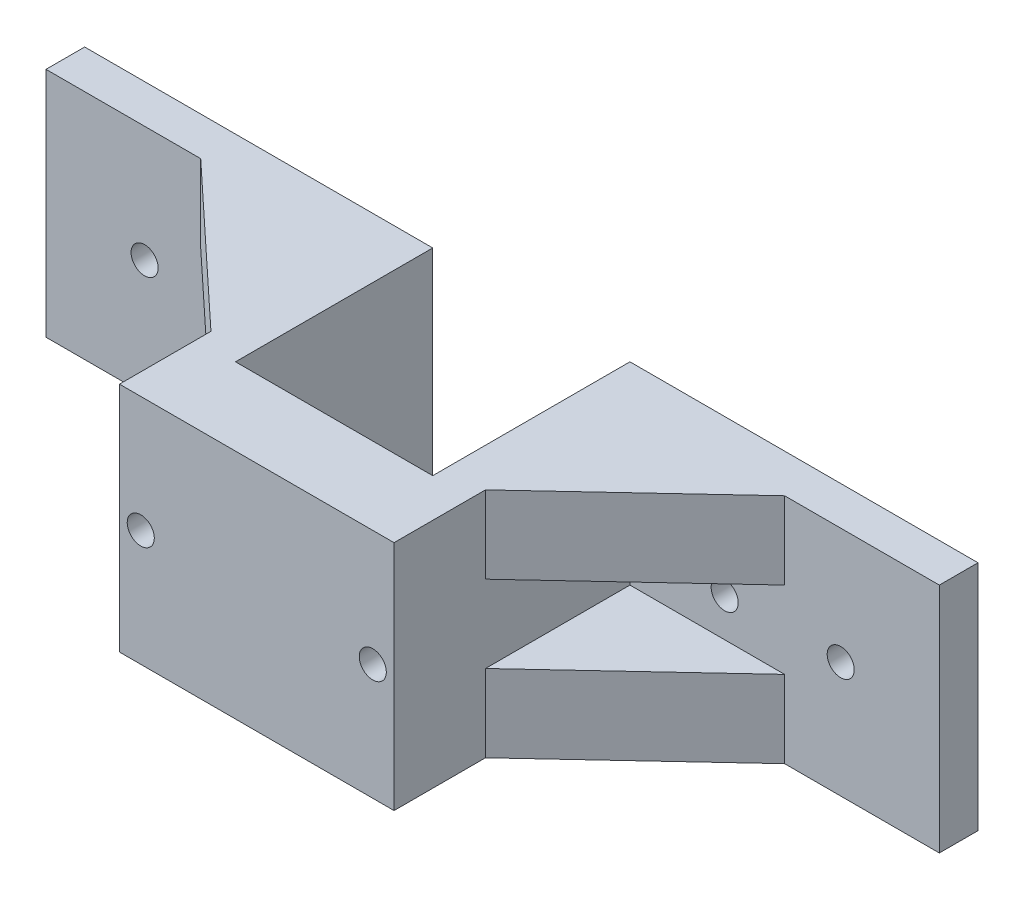
from build123d import *

# Parameters (mm, degrees)
SKETCH_1_W               = 40
SKETCH_1_H               = 30
EXTRUDE_1_DEPTH          = 5
SKETCH_2_W               = 25.5
SKETCH_2_H               = 30
EXTRUDE_2_DEPTH          = 5
SKETCH_3_W               = 5
SKETCH_3_H               = 30
EXTRUDE_3_DEPTH          = 30.5
SKETCH_5_W               = 30.5
SKETCH_5_H               = 30
EXTRUDE_4_DEPTH          = 5
SKETCH_6_W               = 5
SKETCH_6_H               = 30
EXTRUDE_5_DEPTH          = 40
RIB_1_REACH              = 106.645
SKETCH_9_WALL_W          = 238.652565268
SKETCH_9_WALL_H          = 10
MIRROR_2_COPY_1_REACH    = 106.645
MIRROR_2_COPY_1_SKETCH_W = 238.652565268
MIRROR_2_COPY_1_SKETCH_H = 10
SKETCH_10_R              = 1.75
CUT_EXTRUDE_1_DEPTH      = 82
SKETCH_11_R              = 1.75
CUT_EXTRUDE_2_DEPTH      = 40
SKETCH_12_W              = 35.5
SKETCH_12_H              = 30
EXTRUDE_6_DEPTH          = 5
SKETCH_13_R              = 1.75
CUT_EXTRUDE_3_DEPTH      = 66


with BuildPart() as part:
    # 草图1 → 凸台-拉伸1 (new body)
    with BuildSketch(Plane.XY):
        Rectangle(SKETCH_1_W, SKETCH_1_H)
    extrude(amount=EXTRUDE_1_DEPTH)

    # 草图2 → 凸台-拉伸2 (add)
    with BuildSketch(Plane(origin=(20, 0, 0), x_dir=(0, 0, -1), z_dir=(1, 0, 0))):
        with Locations((-12.75, 0)):
            Rectangle(SKETCH_2_W, SKETCH_2_H)
    extrude(amount=EXTRUDE_2_DEPTH)

    # 草图3 → 凸台-拉伸3 (add)
    with BuildSketch(Plane.ZY.offset(-20)):
        with Locations((28, 0)):
            Rectangle(SKETCH_3_W, SKETCH_3_H)
    extrude(amount=-EXTRUDE_3_DEPTH)

    # 草图5 → 凸台-拉伸4 (add)
    with BuildSketch(Plane(origin=(50.5, 0, 0), x_dir=(0, 0, -1), z_dir=(1, 0, 0))):
        with Locations((-15.25, 0)):
            Rectangle(SKETCH_5_W, SKETCH_5_H)
    extrude(amount=EXTRUDE_4_DEPTH)

    # 草图6 → 凸台-拉伸5 (add)
    with BuildSketch(Plane(origin=(55.5, 0, 0), x_dir=(0, 0, -1), z_dir=(1, 0, 0))):
        with Locations((-2.5, 0)):
            Rectangle(SKETCH_6_W, SKETCH_6_H)
    extrude(amount=EXTRUDE_5_DEPTH)

    # 草图9 wall → 筋1 (add, up to next)
    with BuildSketch(Plane(origin=(65.5, -15, 14.337421174), x_dir=(0.730906214245, 0, -0.68247791611), z_dir=(0.68247791611, 0, 0.730906214245)), mode=Mode.PRIVATE) as rib_1_sk1:
        with Locations((0, 5)):
            Rectangle(SKETCH_9_WALL_W, SKETCH_9_WALL_H)
    rib_1_tool1 = extrude(rib_1_sk1.sketch, amount=-RIB_1_REACH, mode=Mode.PRIVATE) - part.part
    rib_1 = rib_1_tool1.solids().sort_by_distance((65.5, -15, 14.337421174))[0]
    add(rib_1)

    # 镜向1: 筋1 across plane
    add(rib_1.mirror(Plane.ZX))

    # 镜向2: 筋1 across plane
    add(rib_1.mirror(Plane(origin=(37.75, 0, 0), x_dir=(0, 0, 1), z_dir=(1, 0, 0))))

    # 镜向2 copy 1 sketch → 镜向2 copy 1 (add, up to next)
    with BuildSketch(Plane(origin=(10, 15, 14.337421174), x_dir=(-0.730906214245, 0, -0.68247791611), z_dir=(-0.68247791611, 0, 0.730906214245)), mode=Mode.PRIVATE) as mirror_2_copy_1_sk1:
        with Locations((0, 5)):
            Rectangle(MIRROR_2_COPY_1_SKETCH_W, MIRROR_2_COPY_1_SKETCH_H)
    mirror_2_copy_1_tool1 = extrude(mirror_2_copy_1_sk1.sketch, amount=-MIRROR_2_COPY_1_REACH, mode=Mode.PRIVATE) - part.part
    add(mirror_2_copy_1_tool1.solids().sort_by_distance((10, 15, 14.337421174))[0])

    # 草图10 → 切除-拉伸1 (cut)
    with BuildSketch(Plane(origin=(0, 0, 0), x_dir=(-1, 0, 0), z_dir=(0, 0, -1))):
        with Locations((-52.75, 0)):
            Circle(SKETCH_10_R)
        with Locations((-22.75, 0)):
            Circle(SKETCH_10_R)
        with Locations((-82.75, 0)):
            Circle(SKETCH_10_R)
        with Locations((7.25, 0)):
            Circle(SKETCH_10_R)
    extrude(amount=-CUT_EXTRUDE_1_DEPTH, mode=Mode.SUBTRACT)

    # 草图11 → 切除-拉伸2 (cut)
    with BuildSketch(Plane(origin=(0, 0, 0), x_dir=(-1, 0, 0), z_dir=(0, 0, -1))):
        with Locations((-67.75, 0)):
            Circle(SKETCH_11_R)
        with Locations(Location((-7.75, 0, 0), (0, 0, 180))):
            Circle(SKETCH_11_R)
    extrude(amount=-CUT_EXTRUDE_2_DEPTH, mode=Mode.SUBTRACT)

    # 草图12 → 凸台-拉伸6 (add)
    with BuildSketch(Plane.XY.offset(30.5)):
        with Locations((37.75, 0)):
            Rectangle(SKETCH_12_W, SKETCH_12_H)
    extrude(amount=EXTRUDE_6_DEPTH)

    # 草图13 → 切除-拉伸3 (cut)
    with BuildSketch(Plane(origin=(0, 0, 0), x_dir=(-1, 0, 0), z_dir=(0, 0, -1))):
        with Locations((-22.75, 0)):
            Circle(SKETCH_13_R)
        with Locations((-52.75, 0)):
            Circle(SKETCH_13_R)
    extrude(amount=-CUT_EXTRUDE_3_DEPTH, mode=Mode.SUBTRACT)


solid = part.part
